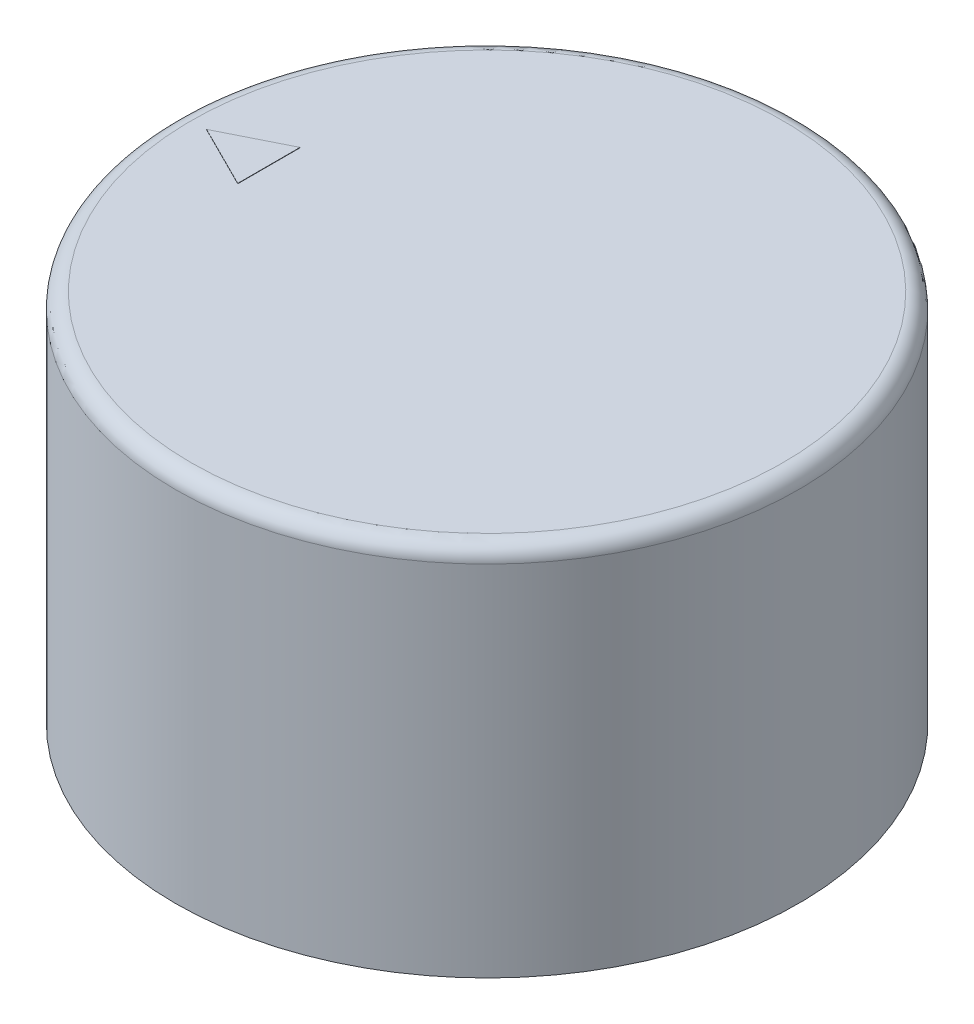
from build123d import *

# Parameters (mm, degrees)
SKETCH1_R           = 10
BOSS_EXTRUDE1_DEPTH = 12
FILLET1_R           = 0.5
SKETCH2_R           = 3
CUT_EXTRUDE1_DEPTH  = 10
BOSS_EXTRUDE2_DEPTH = 0.01


with BuildPart() as part:
    # Sketch1 → Boss-Extrude1 (new body)
    with BuildSketch(Plane(origin=(0, 0, 0), x_dir=(1, 0, 0), z_dir=(0, 1, 0))):
        Circle(SKETCH1_R)
    extrude(amount=BOSS_EXTRUDE1_DEPTH)

    # Fillet1
    fillet1_edges = [part.edges().sort_by_distance(p)[0] for p in [
        (-10, 12, 0),
    ]]
    fillet(fillet1_edges, radius=FILLET1_R)

    # Sketch2 → Cut-Extrude1 (cut)
    with BuildSketch(Plane.XZ):
        Circle(SKETCH2_R)
    extrude(amount=-CUT_EXTRUDE1_DEPTH, mode=Mode.SUBTRACT)

    # Sketch3 → Boss-Extrude2 (add)
    with BuildSketch(Plane(origin=(0, 12, 0), x_dir=(1, 0, 0), z_dir=(0, 1, 0))):
        Polygon((-7, -1), (-7, 1), (-9, 0), align=None)
    extrude(amount=BOSS_EXTRUDE2_DEPTH)


solid = part.part
